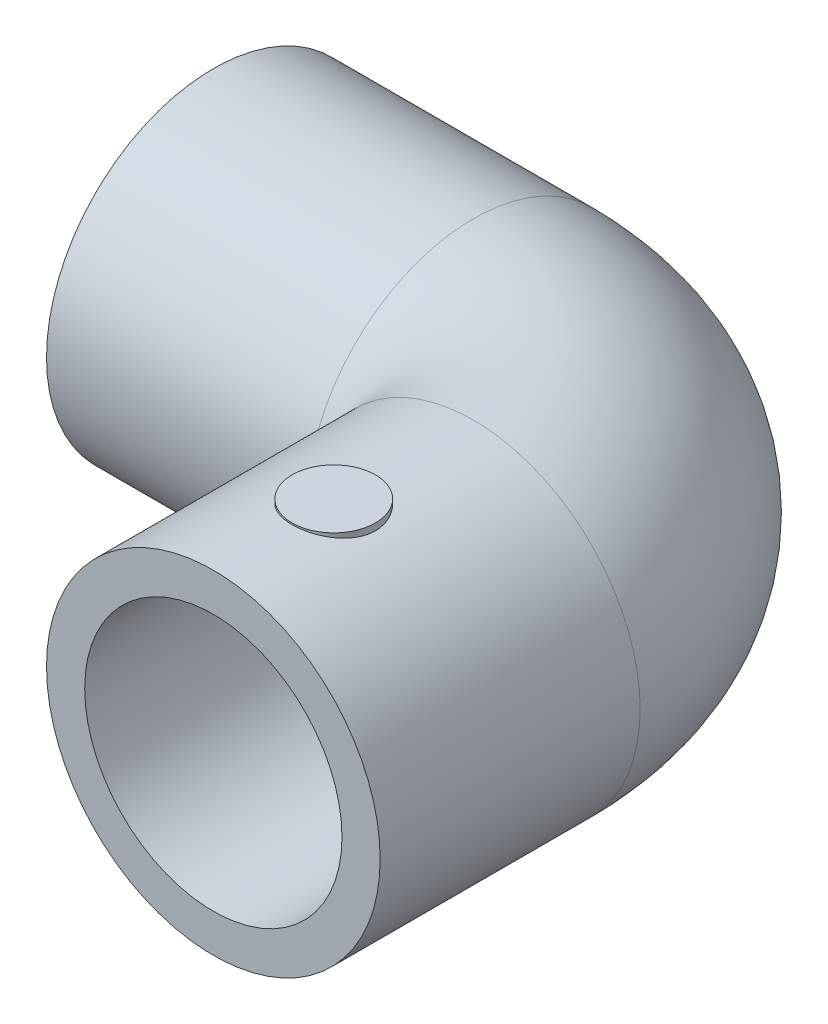
from build123d import *

# Parameters (mm, degrees)
CROQUIS2_R              = 13.875
CROQUIS2_R_2            = 10.7
SALIENTE_EXTRUIR1_START = -22.5
CROQUIS3_R              = 10.7
CROQUIS3_R_2            = 10.003405024
SALIENTE_EXTRUIR1_DEPTH = 1
SALIENTE_EXTRUIR2_START = -22.5
CROQUIS5_R              = 10.7
CROQUIS5_R_2            = 9.69715728
SALIENTE_EXTRUIR2_DEPTH = 1
SALIENTE_EXTRUIR3_START = 14
CROQUIS6_R              = 3.466635683
SALIENTE_EXTRUIR3_DEPTH = 1


with BuildPart() as part:
    # Barrer1: sweep along a path in Croquis1
    with BuildLine(Plane(origin=(0, 0, 0), x_dir=(1, 0, 0), z_dir=(0, 1, 0))) as barrer1_path:
        Line((-36.125, 0), (-14.5, 0))
        ThreePointArc((-14.5, 0), (-4.246951673, -4.246951673), (0, -14.5))
        Line((0, -14.5), (0, -36.125))
    # Croquis2 → Barrer1 (sweep)
    with BuildSketch(Plane.XY.offset(36.125)):
        Circle(CROQUIS2_R)
        Circle(CROQUIS2_R_2, mode=Mode.SUBTRACT)
    sweep(path=barrer1_path.line)

    # Croquis3 → Saliente-Extruir1 (add)
    with BuildSketch(Plane.XY.offset(36.125).offset(SALIENTE_EXTRUIR1_START)):
        Circle(CROQUIS3_R)
        Circle(CROQUIS3_R_2, mode=Mode.SUBTRACT)
    extrude(amount=-SALIENTE_EXTRUIR1_DEPTH)

    # Croquis5 → Saliente-Extruir2 (add)
    with BuildSketch(Plane.ZY.offset(36.125).offset(SALIENTE_EXTRUIR2_START)):
        Circle(CROQUIS5_R)
        Circle(CROQUIS5_R_2, mode=Mode.SUBTRACT)
    extrude(amount=SALIENTE_EXTRUIR2_DEPTH)

    # Croquis6 → Saliente-Extruir3 (add)
    with BuildSketch(Plane(origin=(0, 0, 0), x_dir=(1, 0, 0), z_dir=(0, 1, 0)).offset(SALIENTE_EXTRUIR3_START)):
        with Locations((0, -26.109260765)):
            Circle(CROQUIS6_R)
    extrude(amount=-SALIENTE_EXTRUIR3_DEPTH)


solid = part.part
